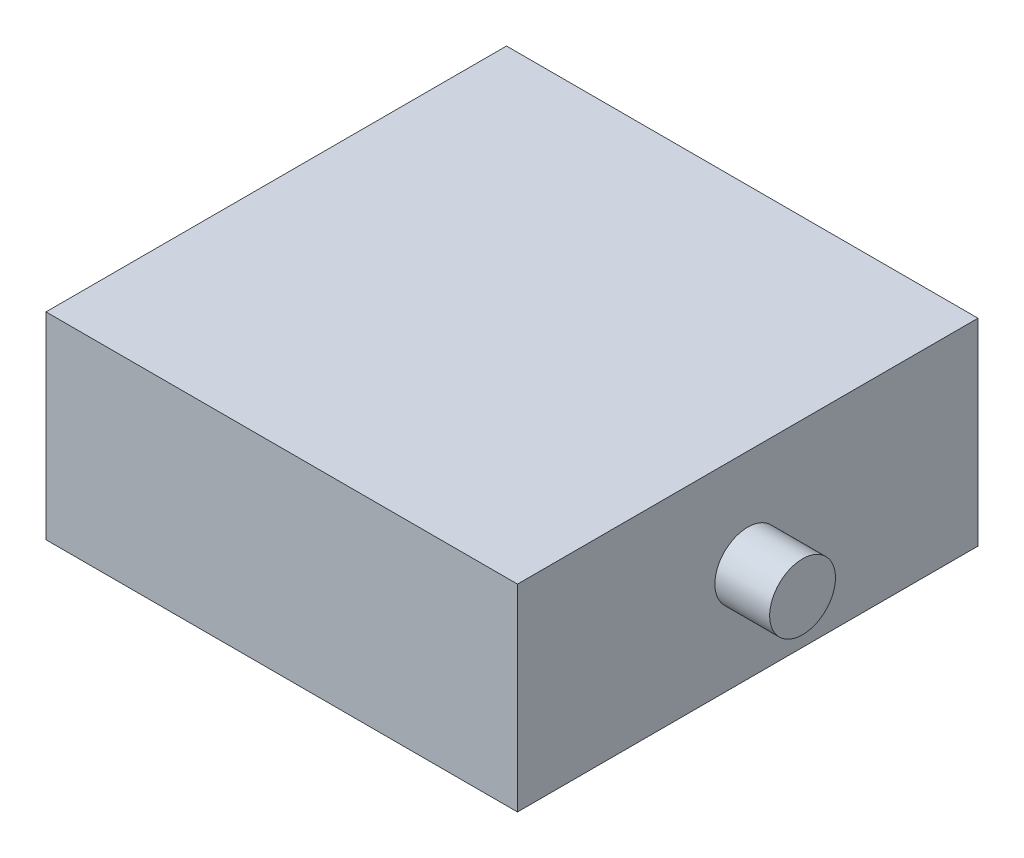
from build123d import *

# Parameters (mm, degrees)
SKETCH2_W           = 48
SKETCH2_H           = 42
BOSS_EXTRUDE1_DEPTH = 18
SKETCH3_W           = 42
SKETCH3_H           = 18
SKETCH3_R           = 3
CUT_EXTRUDE1_DEPTH  = 5


with BuildPart() as part:
    # Sketch2 → Boss-Extrude1 (new body)
    with BuildSketch(Plane(origin=(0, 0, 0), x_dir=(1, 0, 0), z_dir=(0, 1, 0))):
        with Locations((24, 21)):
            Rectangle(SKETCH2_W, SKETCH2_H)
    extrude(amount=BOSS_EXTRUDE1_DEPTH)

    # Sketch3 → Cut-Extrude1 (cut)
    with BuildSketch(Plane(origin=(48, 0, 0), x_dir=(0, 0, -1), z_dir=(1, 0, 0))):
        with Locations((21, 9)):
            Rectangle(SKETCH3_W, SKETCH3_H)
        with Locations((21, 9)):
            Circle(SKETCH3_R, mode=Mode.SUBTRACT)
    extrude(amount=-CUT_EXTRUDE1_DEPTH, mode=Mode.SUBTRACT)


solid = part.part
